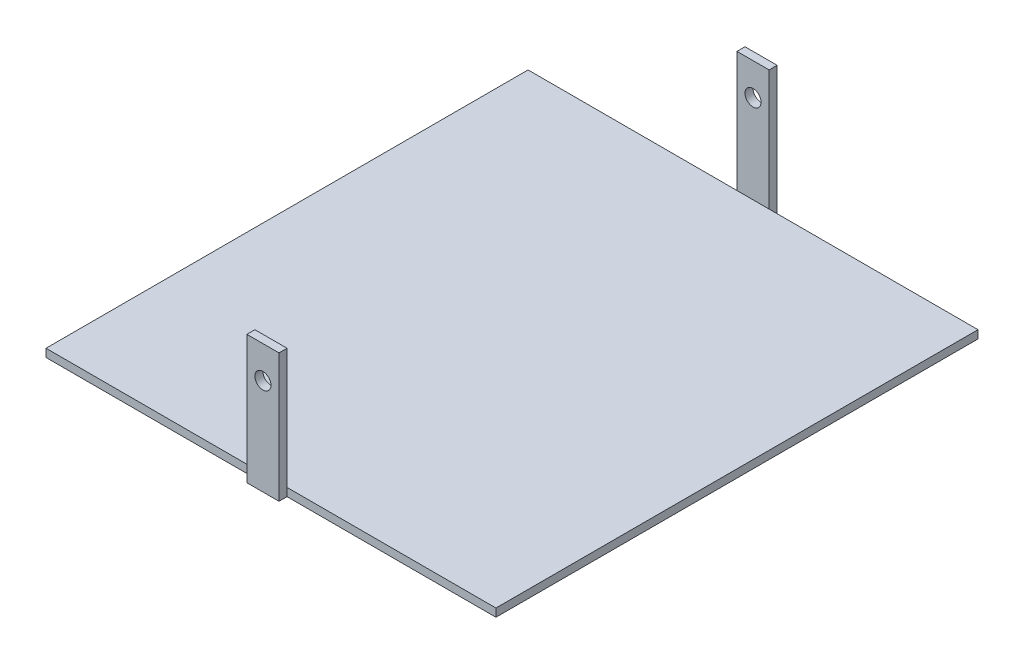
from build123d import *

# Parameters (mm, degrees)
SKETCH1_W           = 280
SKETCH1_H           = 300
BOSS_EXTRUDE1_DEPTH = 5
SKETCH2_W           = 20
SKETCH2_H           = 80
SKETCH2_R           = 5
BOSS_EXTRUDE2_DEPTH = 5


with BuildPart() as part:
    # Sketch1 → Boss-Extrude1 (new body)
    with BuildSketch(Plane(origin=(0, 0, 0), x_dir=(1, 0, 0), z_dir=(0, 1, 0))):
        with Locations((140, 150)):
            Rectangle(SKETCH1_W, SKETCH1_H)
    extrude(amount=BOSS_EXTRUDE1_DEPTH)

    # Sketch2 → Boss-Extrude2 (add)
    with BuildSketch(Plane.XY):
        with Locations((140, 40)):
            Rectangle(SKETCH2_W, SKETCH2_H)
        with Locations((140, 60)):
            Circle(SKETCH2_R, mode=Mode.SUBTRACT)
    boss_extrude2 = extrude(amount=BOSS_EXTRUDE2_DEPTH)

    # Mirror1: Boss-Extrude2 across plane
    add(boss_extrude2.mirror(Plane.XY.offset(-150)))


solid = part.part
